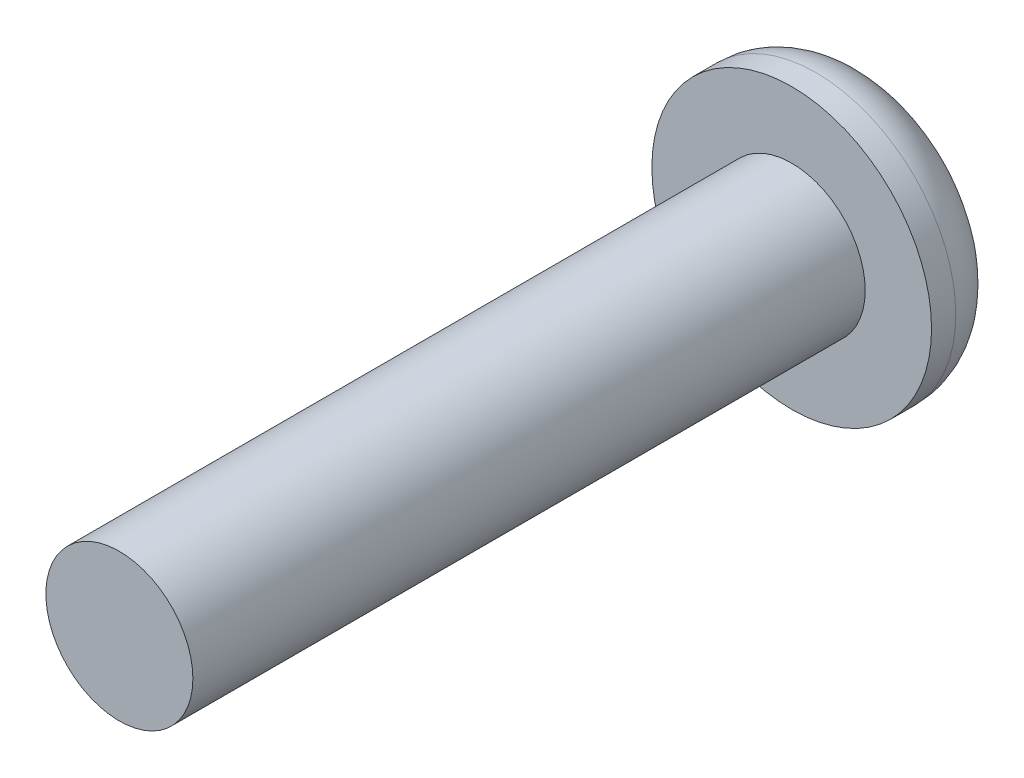
from build123d import *

# Parameters (mm, degrees)
SKETCH1_R      = 3.9624
EXTRUDE1_DEPTH = 2.2098
FILLET1_R      = 1.524
SKETCH2_R      = 2.0828
EXTRUDE2_DEPTH = 19.05
EXTRUDE3_DEPTH = 1.016


with BuildPart() as part:
    # Sketch1 → Extrude1 (new body)
    with BuildSketch(Plane.XY):
        Circle(SKETCH1_R)
    extrude(amount=EXTRUDE1_DEPTH)

    # Fillet1
    fillet1_edges = [part.edges().sort_by_distance(p)[0] for p in [
        (-3.9624, 0, 0),
    ]]
    fillet(fillet1_edges, radius=FILLET1_R)

    # Sketch2 → Extrude2 (add)
    with BuildSketch(Plane.XY.offset(2.2098)):
        Circle(SKETCH2_R)
    extrude(amount=EXTRUDE2_DEPTH)

    # Sketch3 → Extrude3 (cut)
    with BuildSketch(Plane(origin=(0, 0, 0), x_dir=(-1, 0, 0), z_dir=(0, 0, -1))):
        Polygon((0.709024608, 1.177879999), (-0.665561698, 1.202973322), (-1.374586306, 0.025093323), (-0.709024608, -1.177879999), (0.665561698, -1.202973322), (1.374586306, -0.025093323), align=None)
    extrude(amount=-EXTRUDE3_DEPTH, mode=Mode.SUBTRACT)


solid = part.part
